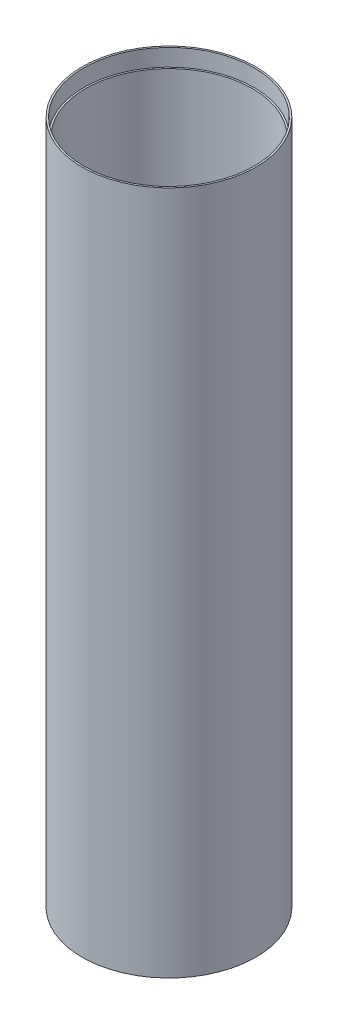
from build123d import *


with BuildPart() as part:
    # Sketch1 → Revolve1 (revolve)
    with BuildSketch(Plane.XY):
        Polygon((127, 1000), (127, 0), (124.5, 0), (124.5, 25), (122, 25), (122, 975), (124.5, 975), (124.5, 1000), align=None)
    revolve(axis=Axis((0, 0, 0), (0, 1, 0)))


solid = part.part
